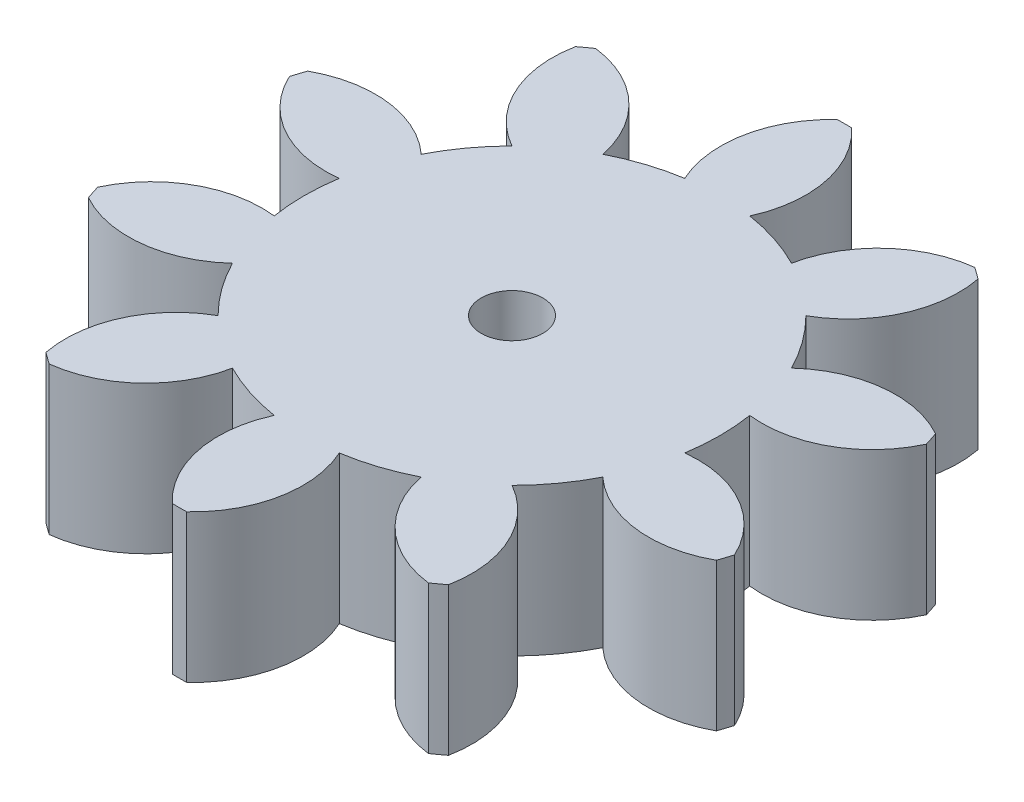
from build123d import *

# Parameters (mm, degrees)
SKETCH1_R           = 2.5
BOSS_EXTRUDE2_DEPTH = 12


with BuildPart() as part:
    # Sketch1 → Boss-Extrude2 (new body)
    with BuildSketch(Plane(origin=(0, 0, 0), x_dir=(1, 0, 0), z_dir=(0, 1, 0))):
        with BuildLine():
            ThreePointArc((45.159534103, 57.054132786), (44.573597006, 57.060491355), (43.987659909, 57.054132786))
            ThreePointArc((43.987659909, 57.054132786), (41.29051652, 52.222505932), (41.929927551, 46.72611129))
            ThreePointArc((41.929927551, 46.72611129), (39.359244243, 46.108619011), (36.916564905, 45.097171022))
            ThreePointArc((36.916564905, 45.097171022), (34.203159585, 49.919684069), (29.181165736, 52.243211197))
            ThreePointArc((29.181165736, 52.243211197), (28.703395194, 51.903950203), (28.233099598, 51.554400828))
            ThreePointArc((28.233099598, 51.554400828), (28.891023769, 46.060191485), (32.639017871, 41.989351186))
            ThreePointArc((32.639017871, 41.989351186), (30.922244243, 39.978779702), (29.540589358, 37.724730199))
            ThreePointArc((29.540589358, 37.724730199), (24.510796293, 40.031325579), (19.082182945, 38.959244591))
            ThreePointArc((19.082182945, 38.959244591), (18.895071066, 38.403950203), (18.720053904, 37.844726003))
            ThreePointArc((18.720053904, 37.844726003), (22.481740965, 33.786535398), (27.90671178, 32.696172074))
            ThreePointArc((27.90671178, 32.696172074), (27.699597006, 30.060491355), (27.90671178, 27.424810636))
            ThreePointArc((27.90671178, 27.424810636), (22.481740964, 26.334447311), (18.720053904, 22.276256707))
            ThreePointArc((18.720053904, 22.276256707), (18.895071066, 21.717032507), (19.082182945, 21.161738118))
            ThreePointArc((19.082182945, 21.161738118), (24.510796293, 20.089657131), (29.540589358, 22.396252511))
            ThreePointArc((29.540589358, 22.396252511), (30.922244243, 20.142203008), (32.639017871, 18.131631524))
            ThreePointArc((32.639017871, 18.131631524), (28.891023769, 14.060791225), (28.233099598, 8.566581881))
            ThreePointArc((28.233099598, 8.566581881), (28.703395194, 8.217032507), (29.181165736, 7.877771512))
            ThreePointArc((29.181165736, 7.877771512), (34.203159585, 10.20129864), (36.916564905, 15.023811688))
            ThreePointArc((36.916564905, 15.023811688), (39.359244243, 14.012363699), (41.929927551, 13.39487142))
            ThreePointArc((41.929927551, 13.39487142), (41.29051652, 7.898476778), (43.987659909, 3.066849924))
            ThreePointArc((43.987659909, 3.066849924), (44.573597006, 3.060491355), (45.159534103, 3.066849924))
            ThreePointArc((45.159534103, 3.066849924), (47.856677493, 7.898476778), (47.217266462, 13.39487142))
            ThreePointArc((47.217266462, 13.39487142), (49.787949769, 14.012363699), (52.230629107, 15.023811688))
            ThreePointArc((52.230629107, 15.023811688), (54.944034428, 10.201298641), (59.966028276, 7.877771513))
            ThreePointArc((59.966028276, 7.877771513), (60.443798818, 8.217032507), (60.914094414, 8.566581881))
            ThreePointArc((60.914094414, 8.566581881), (60.256170243, 14.060791225), (56.508176141, 18.131631524))
            ThreePointArc((56.508176141, 18.131631524), (58.224949769, 20.142203008), (59.606604654, 22.396252511))
            ThreePointArc((59.606604654, 22.396252511), (64.636397719, 20.089657131), (70.065011067, 21.161738118))
            ThreePointArc((70.065011067, 21.161738118), (70.252122946, 21.717032507), (70.427140109, 22.276256707))
            ThreePointArc((70.427140109, 22.276256707), (66.665453048, 26.334447311), (61.240482233, 27.424810636))
            ThreePointArc((61.240482233, 27.424810636), (61.447597006, 30.060491355), (61.240482233, 32.696172074))
            ThreePointArc((61.240482233, 32.696172074), (66.665453048, 33.786535398), (70.427140109, 37.844726003))
            ThreePointArc((70.427140109, 37.844726003), (70.252122946, 38.403950203), (70.065011067, 38.959244591))
            ThreePointArc((70.065011067, 38.959244591), (64.636397719, 40.031325579), (59.606604654, 37.724730199))
            ThreePointArc((59.606604654, 37.724730199), (58.224949769, 39.978779702), (56.508176141, 41.989351186))
            ThreePointArc((56.508176141, 41.989351186), (60.256170243, 46.060191485), (60.914094414, 51.554400828))
            ThreePointArc((60.914094414, 51.554400828), (60.443798818, 51.903950203), (59.966028276, 52.243211197))
            ThreePointArc((59.966028276, 52.243211197), (54.944034428, 49.919684069), (52.230629107, 45.097171022))
            ThreePointArc((52.230629107, 45.097171022), (49.787949769, 46.108619011), (47.217266462, 46.72611129))
            ThreePointArc((47.217266462, 46.72611129), (47.856677493, 52.222505932), (45.159534103, 57.054132786))
        make_face()
        with Locations(Location((44.573597006, 30.060491355, 0), (0, 0, 270))):  # turned: the seam where the file's is
            Circle(SKETCH1_R, mode=Mode.SUBTRACT)
    extrude(amount=BOSS_EXTRUDE2_DEPTH)


solid = part.part
